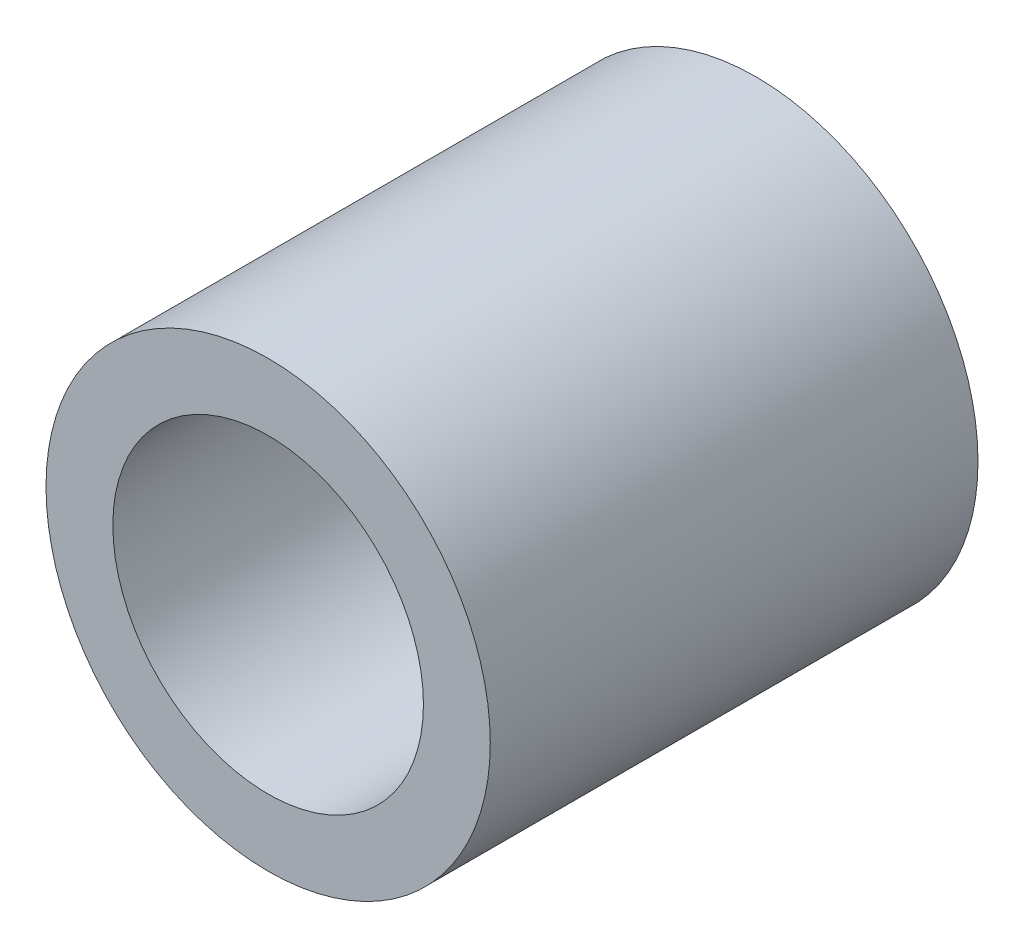
from build123d import *

# Parameters (mm, degrees)
SKETCH1_R           = 10.02
SKETCH1_R_2         = 7.005
BOSS_EXTRUDE1_DEPTH = 11


with BuildPart() as part:
    # Sketch1 → Boss-Extrude1 (new, symmetric)
    with BuildSketch(Plane.XY):
        Circle(SKETCH1_R)
        Circle(SKETCH1_R_2, mode=Mode.SUBTRACT)
    extrude(amount=BOSS_EXTRUDE1_DEPTH, both=True)


solid = part.part
